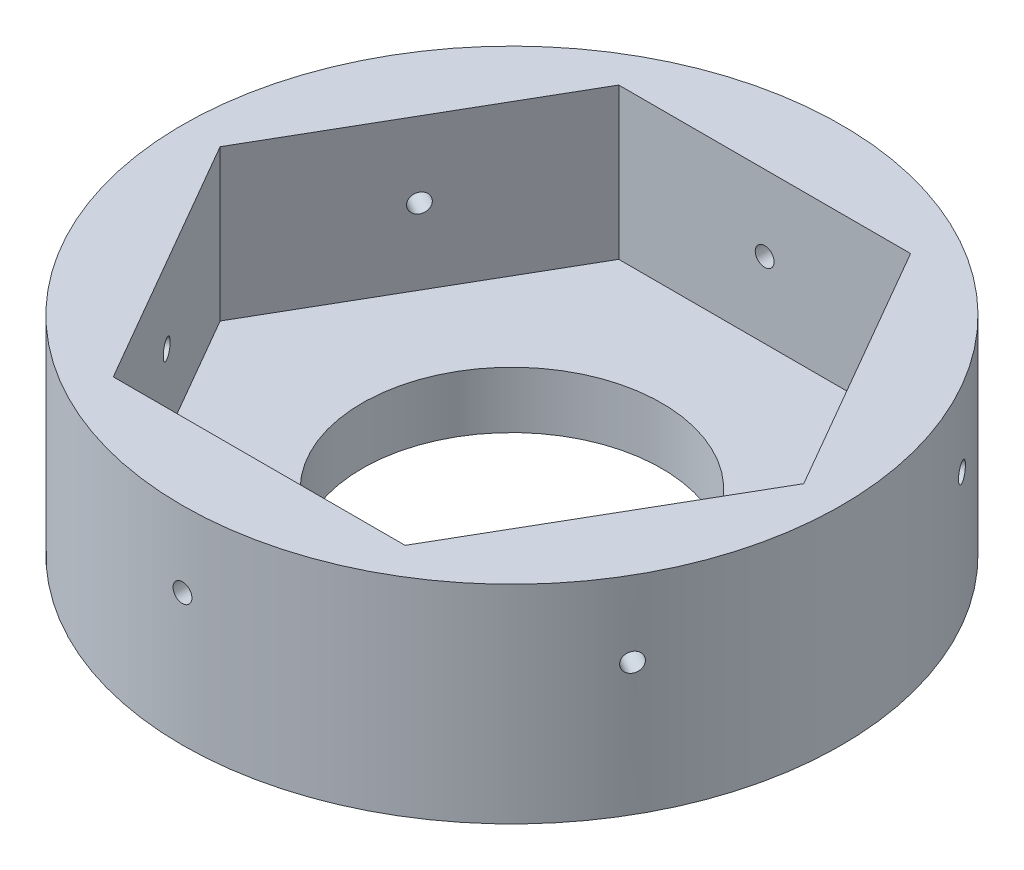
from build123d import *

# Parameters (mm, degrees)
SKETCH1_R                = 77.321
SKETCH1_R_2              = 39.6875
BOSS_EXTRUDE1_DEPTH      = 15
SKETCH2_R                = 87.321
SKETCH2_R_2              = 77.321
BOSS_EXTRUDE2_DEPTH      = 40
BOSS_EXTRUDE2_DEPTH_BACK = 15
BOSS_EXTRUDE3_DEPTH      = 40
SKETCH4_R                = 2.5
CUT_EXTRUDE1_DEPTH       = 21.359049754
CIRPATTERN1_COUNT        = 6


with BuildPart() as part:
    # Sketch1 → Boss-Extrude1 (new body)
    with BuildSketch(Plane(origin=(0, 0, 0), x_dir=(1, 0, 0), z_dir=(0, 1, 0))):
        Circle(SKETCH1_R)
        Circle(SKETCH1_R_2, mode=Mode.SUBTRACT)
    extrude(amount=BOSS_EXTRUDE1_DEPTH)

    # Sketch2 → Boss-Extrude2 (add, two sides)
    with BuildSketch(Plane(origin=(0, 15, 0), x_dir=(1, 0, 0), z_dir=(0, 1, 0))) as boss_extrude2_sk:
        Circle(SKETCH2_R)
        Circle(SKETCH2_R_2, mode=Mode.SUBTRACT)
    extrude(amount=BOSS_EXTRUDE2_DEPTH)
    extrude(boss_extrude2_sk.sketch, amount=-BOSS_EXTRUDE2_DEPTH_BACK)

    # Sketch3 → Boss-Extrude3 (add)
    with BuildSketch(Plane(origin=(0, 15, 0), x_dir=(1, 0, 0), z_dir=(0, 1, 0))):
        with BuildLine():
            ThreePointArc((-77.321, 0), (-66.961950246, -38.6605), (-38.6605, -66.961950246))
            Line((-38.6605, -66.961950246), (-77.321, 0))
        make_face()
        with BuildLine():
            Line((-77.321, 0), (-38.6605, 66.961950246))
            ThreePointArc((-38.6605, 66.961950246), (-66.961950246, 38.6605), (-77.321, 0))
        make_face()
        with BuildLine():
            Line((-38.6605, 66.961950246), (38.6605, 66.961950246))
            ThreePointArc((38.6605, 66.961950246), (0, 77.321), (-38.6605, 66.961950246))
        make_face()
        with BuildLine():
            Line((38.6605, 66.961950246), (77.321, 0))
            ThreePointArc((77.321, 0), (66.961950246, 38.6605), (38.6605, 66.961950246))
        make_face()
        with BuildLine():
            ThreePointArc((38.6605, -66.961950246), (66.961950246, -38.6605), (77.321, 0))
            Line((77.321, 0), (38.6605, -66.961950246))
        make_face()
        with BuildLine():
            ThreePointArc((-38.6605, -66.961950246), (0, -77.321), (38.6605, -66.961950246))
            Line((38.6605, -66.961950246), (-38.6605, -66.961950246))
        make_face()
    extrude(amount=BOSS_EXTRUDE3_DEPTH)

    # Sketch4 → Cut-Extrude1 (cut, through all)
    with BuildSketch(Plane.XY.offset(-66.961950246)):
        with Locations((0, 35)):
            Circle(SKETCH4_R)
    cut_extrude1 = extrude(amount=-CUT_EXTRUDE1_DEPTH, mode=Mode.SUBTRACT)

    # CirPattern1: Cut-Extrude1 ×6 about axis
    cirpattern1_axis = Axis((0, -246.98108496, 0), (0, 1, 0))
    for i in range(1, CIRPATTERN1_COUNT):
        add(cut_extrude1.rotate(cirpattern1_axis, i * 360 / CIRPATTERN1_COUNT), mode=Mode.SUBTRACT)


solid = part.part
